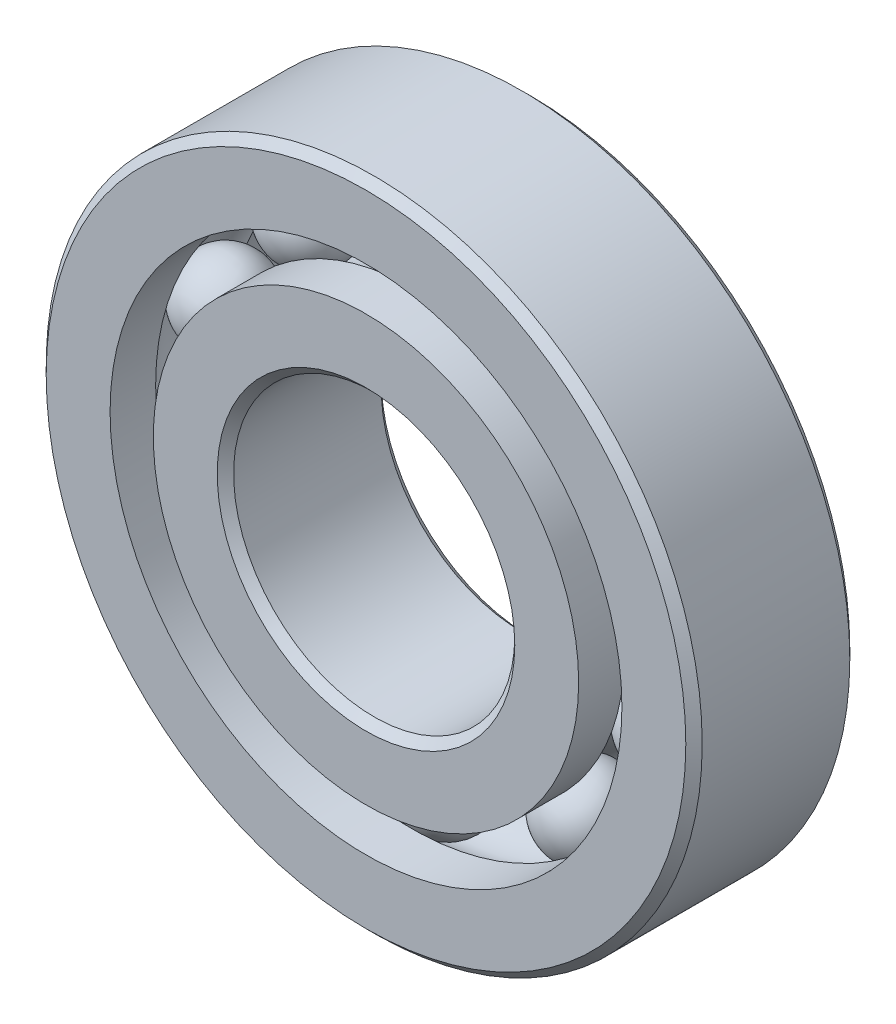
from build123d import *

# Parameters (mm, degrees)
CIRPATTERN1_COUNT = 10


with BuildPart() as part:
    # Sketch1 → Revolve1 (revolve)
    with BuildSketch(Plane(origin=(0, 0, 0), x_dir=(0, 0, -1), z_dir=(1, 0, 0))):
        with BuildLine():
            Line((2.5003125, 11.1125), (-2.5003125, 11.1125))
            Line((-2.5003125, 11.1125), (-2.778125, 10.8346875))
            Line((-2.778125, 10.8346875), (-2.778125, 8.670192308))
            Line((-2.778125, 8.670192308), (-1.234722222, 8.670192308))
            ThreePointArc((-1.234722222, 8.670192308), (0, 9.373249624), (1.234722222, 8.670192308))
            Line((1.234722222, 8.670192308), (2.778125, 8.670192308))
            Line((2.778125, 8.670192308), (2.778125, 10.8346875))
            Line((2.778125, 10.8346875), (2.5003125, 11.1125))
        make_face()
    revolve(axis=Axis((0, 0, 2.778125), (0, 0, -1)))


with BuildPart() as body_2:
    # Sketch3 → Revolve3 (revolve)
    with BuildSketch(Plane(origin=(0, 0, 0), x_dir=(0, 0, -1), z_dir=(1, 0, 0))):
        with BuildLine():
            Line((-2.778125, 7.204807692), (-1.234722222, 7.204807692))
            ThreePointArc((-1.234722222, 7.204807692), (0, 6.501750376), (1.234722222, 7.204807692))
            Line((1.234722222, 7.204807692), (2.778125, 7.204807692))
            Line((2.778125, 7.204807692), (2.778125, 5.0403125))
            Line((2.778125, 5.0403125), (2.5003125, 4.7625))
            Line((2.5003125, 4.7625), (-2.5003125, 4.7625))
            Line((-2.5003125, 4.7625), (-2.778125, 5.0403125))
            Line((-2.778125, 5.0403125), (-2.778125, 7.204807692))
        make_face()
    revolve(axis=Axis((0, 0, 2.778125), (0, 0, -1)))


with BuildPart() as body_3:
    # Sketch4 → Revolve4 (revolve)
    with BuildSketch(Plane(origin=(0, 0, 0), x_dir=(0, 0, -1), z_dir=(1, 0, 0))):
        with BuildLine():
            Line((-1.435749624, 7.9375), (1.435749624, 7.9375))
            ThreePointArc((1.435749624, 7.9375), (0, 9.373249624), (-1.435749624, 7.9375))
        make_face()
    revolve(axis=Axis((0, 7.9375, 1.435749624), (0, 0, -1)))


with BuildPart() as cirpattern1_1:
    # CirPattern1: pattern copy
    add(body_3.part.rotate(Axis((0, 0, 0), (0, 0, 1)), 1 * 360 / CIRPATTERN1_COUNT))


with BuildPart() as cirpattern1_2:
    # CirPattern1: pattern copy
    add(body_3.part.rotate(Axis((0, 0, 0), (0, 0, 1)), 2 * 360 / CIRPATTERN1_COUNT))


with BuildPart() as cirpattern1_3:
    # CirPattern1: pattern copy
    add(body_3.part.rotate(Axis((0, 0, 0), (0, 0, 1)), 3 * 360 / CIRPATTERN1_COUNT))


with BuildPart() as cirpattern1_4:
    # CirPattern1: pattern copy
    add(body_3.part.rotate(Axis((0, 0, 0), (0, 0, 1)), 4 * 360 / CIRPATTERN1_COUNT))


with BuildPart() as cirpattern1_5:
    # CirPattern1: pattern copy
    add(body_3.part.rotate(Axis((0, 0, 0), (0, 0, 1)), 5 * 360 / CIRPATTERN1_COUNT))


with BuildPart() as cirpattern1_6:
    # CirPattern1: pattern copy
    add(body_3.part.rotate(Axis((0, 0, 0), (0, 0, 1)), 6 * 360 / CIRPATTERN1_COUNT))


with BuildPart() as cirpattern1_7:
    # CirPattern1: pattern copy
    add(body_3.part.rotate(Axis((0, 0, 0), (0, 0, 1)), 7 * 360 / CIRPATTERN1_COUNT))


with BuildPart() as cirpattern1_8:
    # CirPattern1: pattern copy
    add(body_3.part.rotate(Axis((0, 0, 0), (0, 0, 1)), 8 * 360 / CIRPATTERN1_COUNT))


with BuildPart() as cirpattern1_9:
    # CirPattern1: pattern copy
    add(body_3.part.rotate(Axis((0, 0, 0), (0, 0, 1)), 9 * 360 / CIRPATTERN1_COUNT))


solid = Compound([part.part, body_2.part, body_3.part, cirpattern1_1.part, cirpattern1_2.part, cirpattern1_3.part, cirpattern1_4.part, cirpattern1_5.part, cirpattern1_6.part, cirpattern1_7.part, cirpattern1_8.part, cirpattern1_9.part])
